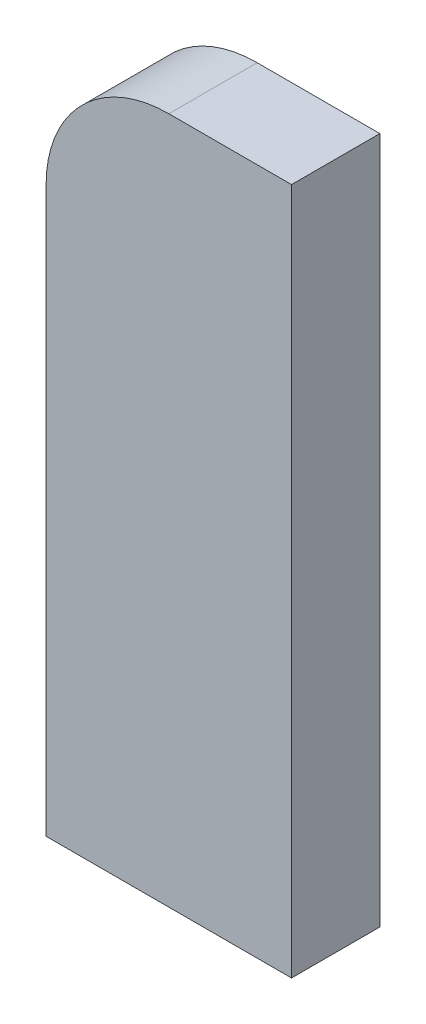
from build123d import *

# Parameters (mm, degrees)
BOSS_EXTRUDE1_DEPTH = 9


with BuildPart() as part:
    # Sketch1 → Boss-Extrude1 (new body)
    with BuildSketch(Plane.XY):
        with BuildLine():
            Line((0, 0), (25, 0))
            Line((25, 0), (25, 70))
            Line((25, 70), (12.5, 70))
            ThreePointArc((12.5, 70), (3.661165235, 66.338834765), (0, 57.5))
            Line((0, 57.5), (0, 0))
        make_face()
    extrude(amount=BOSS_EXTRUDE1_DEPTH)


solid = part.part
